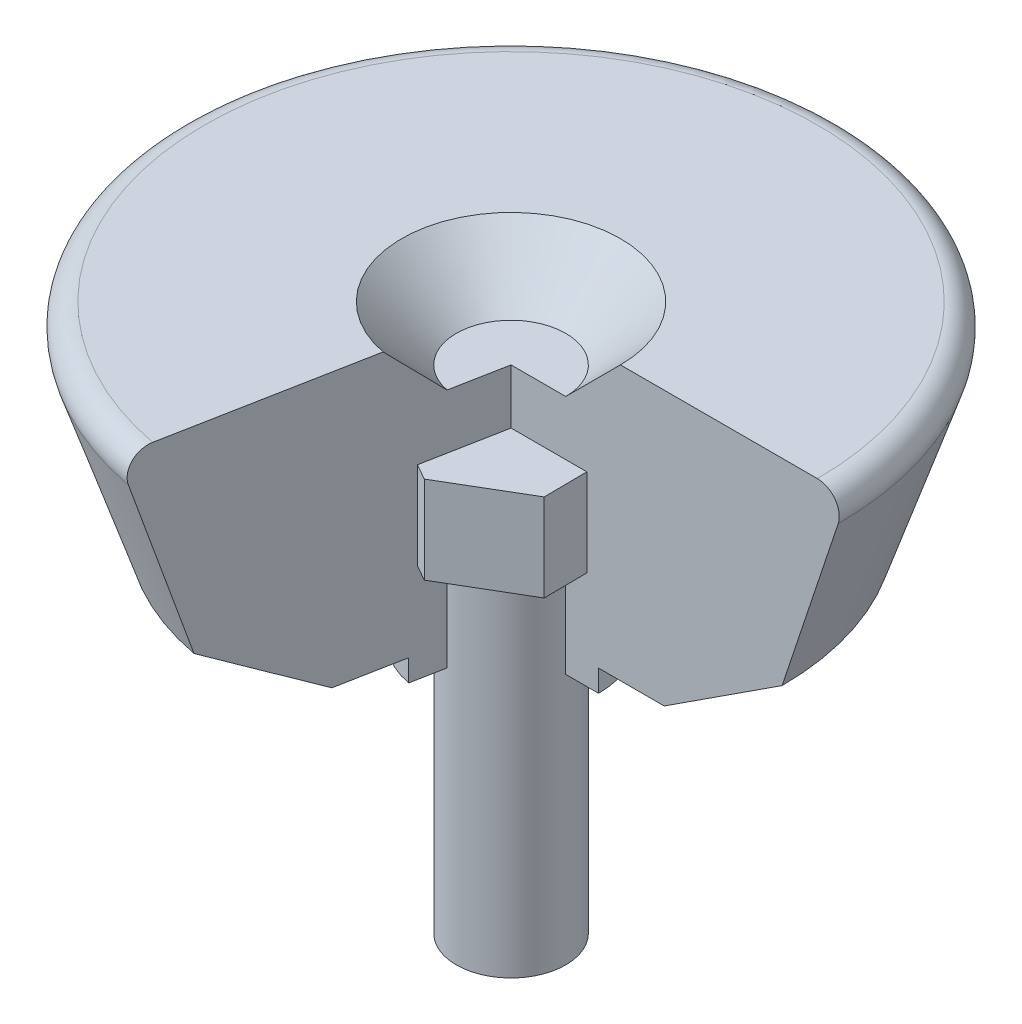
from build123d import *

# Parameters (mm, degrees)
REVOLVE_2_ANGLE = 259.2
SKETCH_5_R      = 10
SKETCH_6_R      = 5
EXTRUDE_1_DEPTH = 8
SKETCH_8_R      = 5
EXTRUDE_2_DEPTH = 32


with BuildPart() as part:
    # Эскиз4 → Повернуть2 (revolve)
    with BuildSketch(Plane.XY):
        with BuildLine():
            Line((0, 23), (8, 23))
            Line((8, 23), (8, 25))
            Line((8, 25), (14, 25))
            Line((14, 25), (24.774851773, 32))
            Line((24.774851773, 32), (29.897366596, 47.367544468))
            ThreePointArc((29.897366596, 47.367544468), (29.62248437, 49.169420569), (28, 50))
            Line((28, 50), (0, 50))
            Line((0, 50), (0, 23))
        make_face()
    revolve(axis=Axis((0, 0, 0), (0, 1, 0)), revolution_arc=REVOLVE_2_ANGLE)

    # Эскиз5 → Вырез-По сечениям1 section 0
    with BuildSketch(Plane(origin=(0, 50, 0), x_dir=(1, 0, 0), z_dir=(0, 1, 0))):
        Circle(SKETCH_5_R)
    # Эскиз6 → Вырез-По сечениям1 section 1
    with BuildSketch(Plane(origin=(0, 45, 0), x_dir=(1, 0, 0), z_dir=(0, 1, 0))):
        Circle(SKETCH_6_R)
    loft(mode=Mode.SUBTRACT)


with BuildPart() as body_2:
    # Эскиз7 → Бобышка-Вытянуть1 (new body)
    with BuildSketch(Plane(origin=(0, 40, 0), x_dir=(1, 0, 0), z_dir=(0, 1, 0))):
        Polygon((-0.073107163, 7.999665952), (-6.964467518, 3.936520315), (-6.891360355, -4.063145636), (0.073107163, -7.999665952), (6.964467518, -3.936520315), (6.891360355, 4.063145636), align=None)
    extrude(amount=-EXTRUDE_1_DEPTH)


with BuildPart() as body_3:
    # Эскиз8 → Бобышка-Вытянуть2 (new body)
    with BuildSketch(Plane(origin=(0, 32, 0), x_dir=(1, 0, 0), z_dir=(0, 1, 0))):
        Circle(SKETCH_8_R)
    extrude(amount=-EXTRUDE_2_DEPTH)


solid = Compound([part.part, body_2.part, body_3.part])
